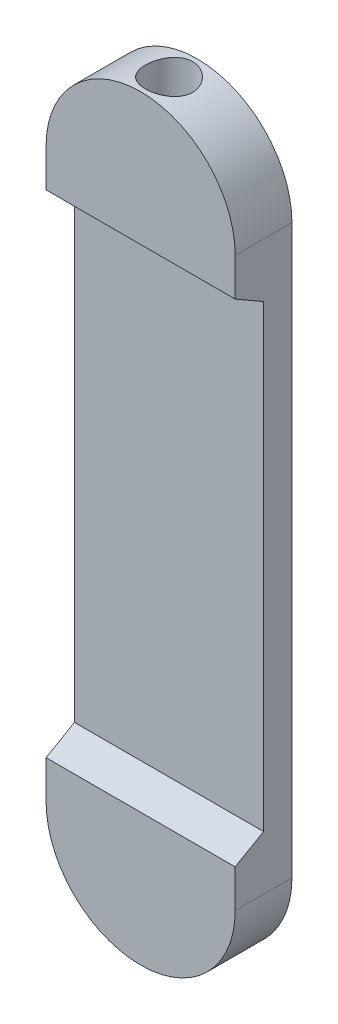
from build123d import *

# Parameters (mm, degrees)
BOSS_EXTRUDE1_DEPTH = 15
SKETCH5_R           = 12.5
CUT_EXTRUDE1_DEPTH  = 59
CUT_EXTRUDE3_DEPTH  = 110
SKETCH10_R          = 12.5
CUT_EXTRUDE4_DEPTH  = 94


with BuildPart() as part:
    # Sketch2 → Boss-Extrude1 (new body, symmetric)
    with BuildSketch(Plane.XY):
        with BuildLine():
            Line((-50, -150), (-50, 150))
            ThreePointArc((-50, 150), (0, 200), (50, 150))
            Line((50, 150), (50, -150))
            ThreePointArc((50, -150), (0, -200), (-50, -150))
        make_face()
    extrude(amount=BOSS_EXTRUDE1_DEPTH, both=True)

    # Sketch5 → Cut-Extrude1 (cut)
    with BuildSketch(Plane(origin=(0, 150, 0), x_dir=(1, 0, 0), z_dir=(0, 1, 0))):
        Circle(SKETCH5_R)
    extrude(amount=CUT_EXTRUDE1_DEPTH, mode=Mode.SUBTRACT)

    # Sketch7 → Cut-Extrude3 (cut)
    with BuildSketch(Plane(origin=(50, 0, 0), x_dir=(0, 0, -1), z_dir=(1, 0, 0))):
        Polygon((-15, 130), (0, 121.339745962), (0, -121.339745962), (-15, -130), align=None)
    extrude(amount=-CUT_EXTRUDE3_DEPTH, mode=Mode.SUBTRACT)

    # Sketch10 → Cut-Extrude4 (cut)
    with BuildSketch(Plane(origin=(0, -150, 0), x_dir=(1, 0, 0), z_dir=(0, 1, 0))):
        Circle(SKETCH10_R)
    extrude(amount=-CUT_EXTRUDE4_DEPTH, mode=Mode.SUBTRACT)


solid = part.part
